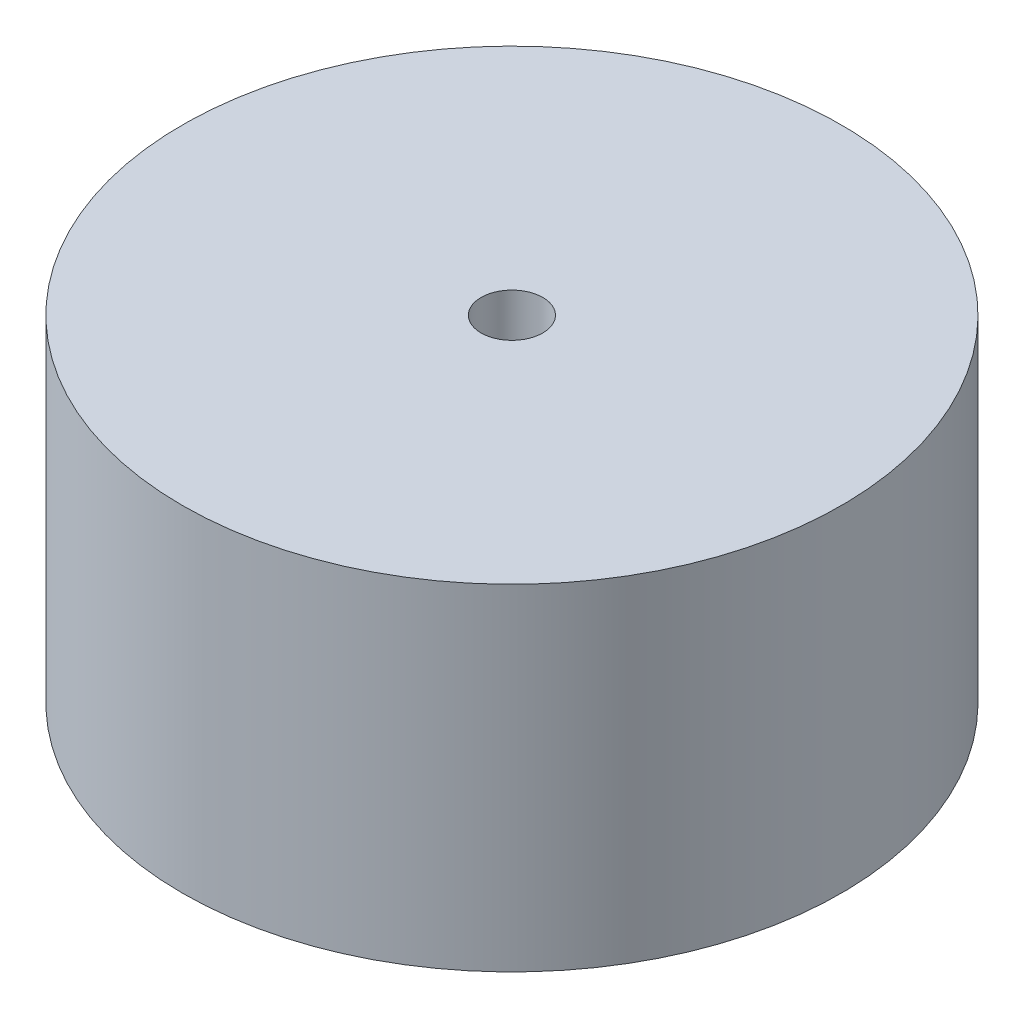
from build123d import *

# Parameters (mm, degrees)
SKETCH1_R           = 17.375
BOSS_EXTRUDE1_DEPTH = 17.7
SKETCH7_R           = 13.545
CUT_EXTRUDE4_DEPTH  = 8
SKETCH10_R          = 3.485
BOSS_EXTRUDE3_DEPTH = 4
SKETCH11_R          = 1.625
CUT_EXTRUDE5_DEPTH  = 13.7


with BuildPart() as part:
    # Sketch1 → Boss-Extrude1 (new body)
    with BuildSketch(Plane(origin=(0, 0, 0), x_dir=(1, 0, 0), z_dir=(0, 1, 0))):
        Circle(SKETCH1_R)
    extrude(amount=BOSS_EXTRUDE1_DEPTH)

    # Sketch7 → Cut-Extrude4 (cut)
    with BuildSketch(Plane.XZ):
        Circle(SKETCH7_R)
    extrude(amount=-CUT_EXTRUDE4_DEPTH, mode=Mode.SUBTRACT)

    # Sketch10 → Boss-Extrude3 (add)
    with BuildSketch(Plane.XZ.offset(-8)):
        Circle(SKETCH10_R)
    extrude(amount=BOSS_EXTRUDE3_DEPTH)

    # Sketch11 → Cut-Extrude5 (cut)
    with BuildSketch(Plane.XZ.offset(-4)):
        Circle(SKETCH11_R)
    extrude(amount=-CUT_EXTRUDE5_DEPTH, mode=Mode.SUBTRACT)


solid = part.part
